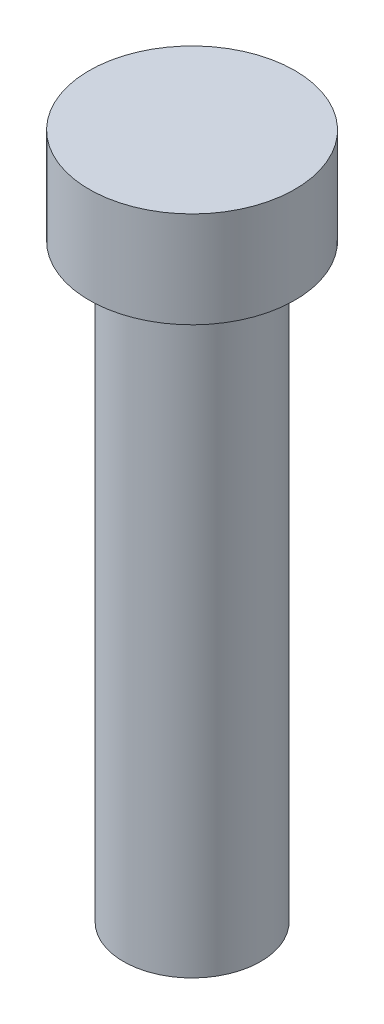
from build123d import *


with BuildPart() as part:
    # Sketch1 → Revolve1 (revolve)
    with BuildSketch(Plane.XY):
        Polygon((5, 0), (5, 43), (7.5, 43), (7.5, 50), (0, 50), (0, 0), align=None)
    revolve(axis=Axis((0, 0, 0), (0, 1, 0)))


solid = part.part
